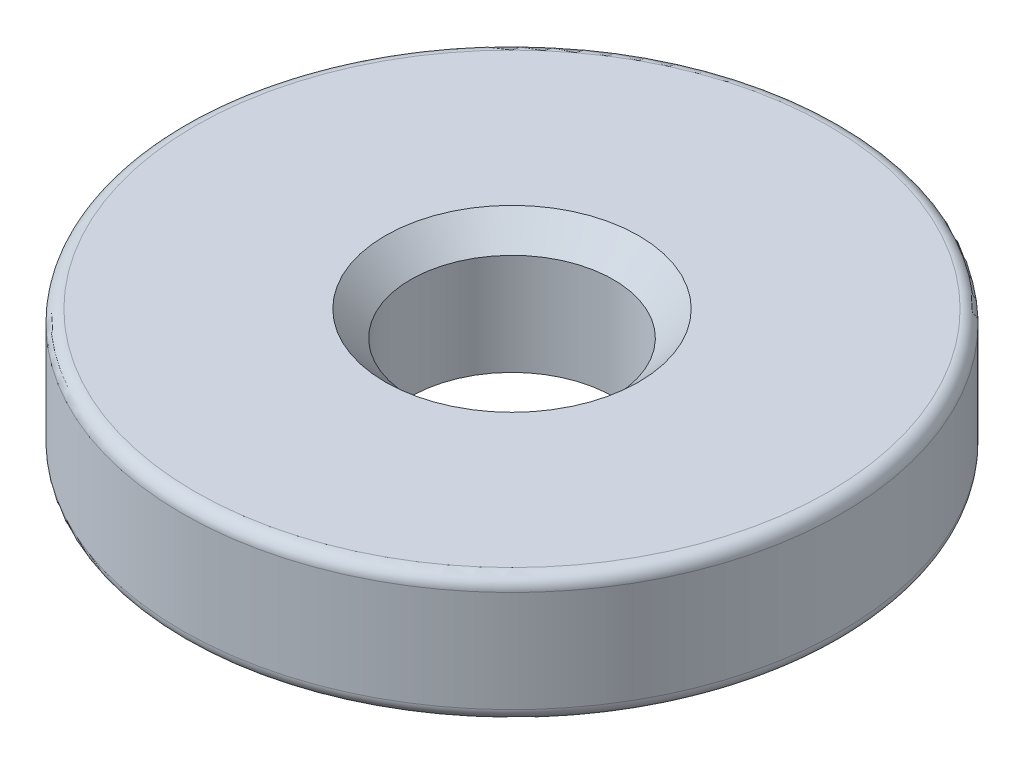
from build123d import *

# Parameters (mm, degrees)
SKETCH1_R           = 13
SKETCH1_R_2         = 4
BOSS_EXTRUDE1_DEPTH = 5
CHAMFER1_SIZE       = 1
FILLET1_R           = 0.5


with BuildPart() as part:
    # Sketch1 → Boss-Extrude1 (new body)
    with BuildSketch(Plane(origin=(0, 0, 0), x_dir=(1, 0, 0), z_dir=(0, 1, 0))):
        Circle(SKETCH1_R)
        Circle(SKETCH1_R_2, mode=Mode.SUBTRACT)
    extrude(amount=BOSS_EXTRUDE1_DEPTH)

    # Chamfer1
    chamfer1_edges = [part.edges().sort_by_distance(p)[0] for p in [
        (-4, 5, 0),
    ]]
    chamfer(chamfer1_edges, length=CHAMFER1_SIZE)

    # Fillet1
    fillet1_edges = [part.edges().sort_by_distance(p)[0] for p in [
        (-13, 0, 0),
        (-13, 5, 0),
    ]]
    fillet(fillet1_edges, radius=FILLET1_R)


solid = part.part
